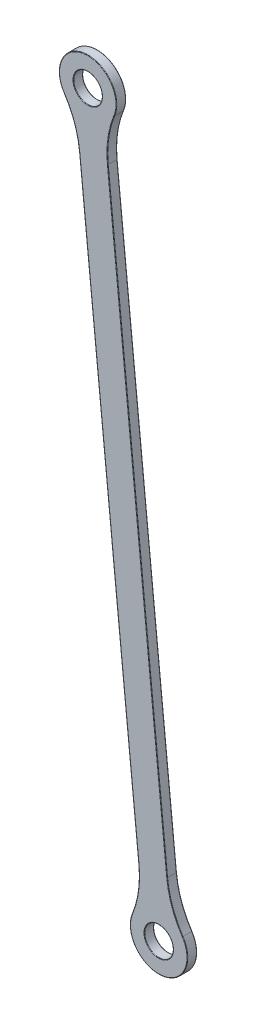
from build123d import *

# Parameters (mm, degrees)
BOSS_EXTRUDE1_DEPTH = 3
FILLET1_R           = 30
FILLET2_R           = 0.15


with BuildPart() as part:
    # Sketch1 → Boss-Extrude1 (new body)
    with BuildSketch(Plane.XY):
        with BuildLine():
            ThreePointArc((9.239986784, 88.802894013), (15.403858063, 72.545501655), (18.194485129, 89.706752076))
            Line((18.194485129, 89.706752076), (18.977249172, 81.951929031))
            ThreePointArc((18.977249172, 81.951929031), (14.951929031, 77.022750828), (10.022750828, 81.048070969))
            Line((10.022750828, 81.048070969), (9.239986784, 88.802894013))
        make_face()
        with BuildLine():
            Line((-3.317916372, 302.829554864), (18.977249172, 81.951929031))
            ThreePointArc((18.977249172, 81.951929031), (14.048070969, 85.977249172), (10.022750828, 81.048070969))
            Line((10.022750828, 81.048070969), (-12.272414716, 301.925696801))
            ThreePointArc((-12.272414716, 301.925696801), (-7.343236513, 297.90037666), (-3.317916372, 302.829554864))
        make_face()
        with BuildLine():
            ThreePointArc((-12.272414716, 301.925696801), (-8.247094575, 306.854875005), (-3.317916372, 302.829554864))
            Line((-3.317916372, 302.829554864), (-2.535152328, 295.074731819))
            ThreePointArc((-2.535152328, 295.074731819), (-8.699023607, 311.332124177), (-11.489650673, 294.170873757))
            Line((-11.489650673, 294.170873757), (-12.272414716, 301.925696801))
        make_face()
    extrude(amount=-BOSS_EXTRUDE1_DEPTH)

    # Fillet1
    fillet1_edges = [part.edges().sort_by_distance(p)[0] for p in [
        (18.194485129, 89.706752076, -1.5),
        (9.239986784, 88.802894013, -1.5),
        (-11.489650673, 294.170873757, -1.5),
        (-2.535152328, 295.074731819, -1.5),
    ]]
    fillet(fillet1_edges, radius=FILLET1_R)

    # Fillet2
    fillet2_edges = [part.edges().sort_by_distance(p)[0] for p in [
        (-1.124831944, 191.486883885, 0),
        (-1.124831944, 191.486883885, -3),
        (15.403858063, 72.545501655, 0),
        (15.403858063, 72.545501655, -3),
        (10.022750828, 81.048070969, -3),
        (7.8296664, 192.390741948, 0),
        (7.8296664, 192.390741948, -3),
        (-8.699023607, 311.332124177, 0),
        (-8.699023607, 311.332124177, -3),
        (8.04616746, 91.885121184, 0),
        (8.04616746, 91.885121184, -3),
        (18.748264899, 92.965380142, 0),
        (18.748264899, 92.965380142, -3),
        (-7.343236513, 297.90037666, -3),
        (-12.043430442, 290.91224569, 0),
        (-12.043430442, 290.91224569, -3),
        (-1.341333004, 291.992504649, 0),
        (-1.341333004, 291.992504649, -3),
        (-7.343236513, 297.90037666, 0),
        (10.022750828, 81.048070969, 0),
    ]]
    fillet(fillet2_edges, radius=FILLET2_R)


solid = part.part
